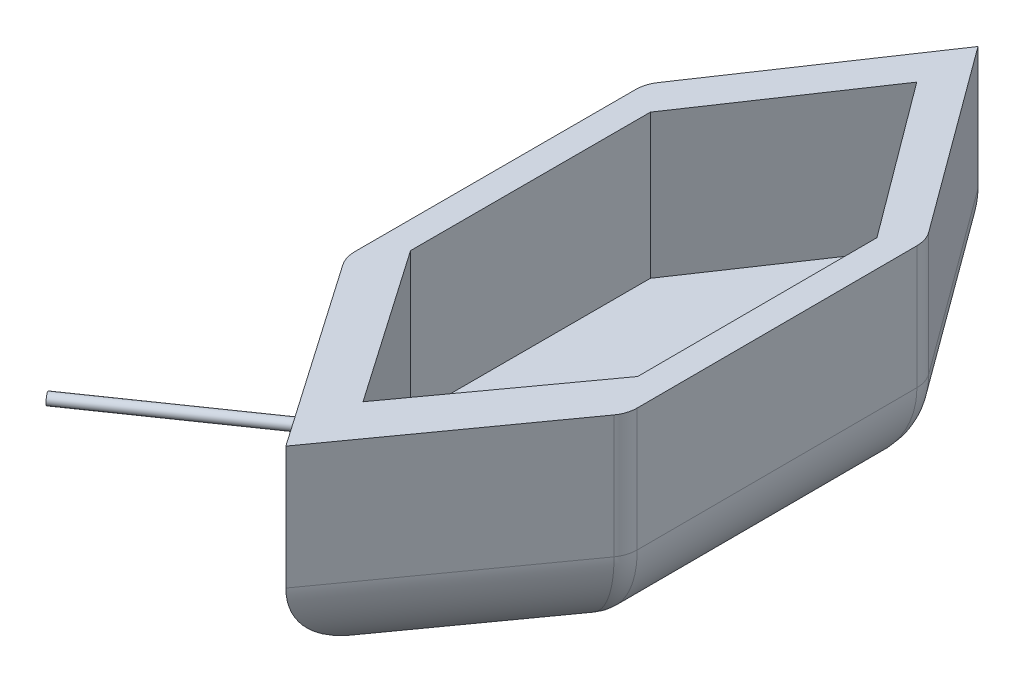
from build123d import *

# Parameters (mm, degrees)
BOSS_EXTRUDE1_DEPTH = 71
CUT_EXTRUDE1_DEPTH  = 48
FILLET1_R           = 30
FILLET2_R           = 10
SKETCH3_R           = 1.773463316
BOSS_EXTRUDE2_DEPTH = 64


with BuildPart() as part:
    # Sketch1 → Boss-Extrude1 (new body)
    with BuildSketch(Plane(origin=(0, 0, 0), x_dir=(1, 0, 0), z_dir=(0, 1, 0))):
        Polygon((-53.484564952, 104.184508732), (-98.158322107, 37.819944229), (-98.158322107, -62.180055771), (-53.484564952, -126.659696939), (-5.888781519, -60.295132437), (-6.131233796, 39.704573647), align=None)
    extrude(amount=BOSS_EXTRUDE1_DEPTH)

    # Sketch2 → Cut-Extrude1 (cut)
    with BuildSketch(Plane(origin=(0, 71, 0), x_dir=(1, 0, 0), z_dir=(0, 1, 0))):
        Polygon((-53.419316383, 83.690098923), (-89.158322107, 30.598447321), (-89.158322107, -49.401552679), (-53.419316383, -100.985265614), (-14.918881702, -47.891189489), (-15.112843524, 32.108575378), align=None)
    extrude(amount=-CUT_EXTRUDE1_DEPTH, mode=Mode.SUBTRACT)

    # Fillet1
    fillet1_edges = [part.edges().sort_by_distance(p)[0] for p in [
        (-6.010007658, 0, 10.295279395),
        (-29.686673235, 0, 93.477414688),
        (-75.821443529, 0, 94.419876355),
        (-98.158322107, 0, 12.180055771),
        (-75.821443529, 0, -71.002226481),
        (-29.807899374, 0, -71.94454119),
    ]]
    fillet(fillet1_edges, radius=FILLET1_R)

    # Fillet2
    fillet2_edges = [part.edges().sort_by_distance(p)[0] for p in [
        (-6.131233796, 50.5, -39.704573647),
        (-5.888781519, 50.5, 60.295132437),
        (-98.158322107, 50.5, 62.180055771),
        (-98.158322107, 50.5, -37.819944229),
        (-15.180720611, 8.520303105, -36.726448686),
        (-14.946943145, 8.525742818, 57.394836212),
        (-89.134201731, 8.55209861, -35.065579718),
        (-89.123112182, 8.541258724, 59.355901315),
    ]]
    fillet(fillet2_edges, radius=FILLET2_R)

    # Sketch3 → Boss-Extrude2 (add)
    with BuildSketch(Plane(origin=(-95.430334367, 0, 66.117483062), x_dir=(0.569502992, 0, 0.821989259), z_dir=(-0.821989259, 0, 0.569502992))):
        with Locations((35.994445749, 50.5)):
            Circle(SKETCH3_R)
    extrude(amount=BOSS_EXTRUDE2_DEPTH)


solid = part.part
